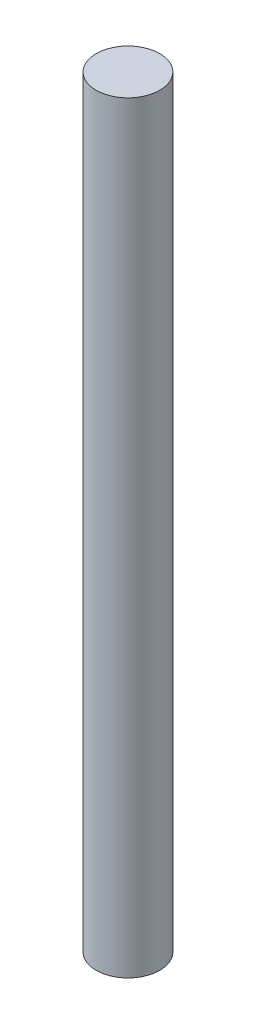
from build123d import *

# Parameters (mm, degrees)
SKETCH1_R           = 30
BOSS_EXTRUDE1_DEPTH = 720


with BuildPart() as part:
    # Sketch1 → Boss-Extrude1 (new body)
    with BuildSketch(Plane(origin=(0, 0, 0), x_dir=(1, 0, 0), z_dir=(0, 1, 0))):
        Circle(SKETCH1_R)
    extrude(amount=BOSS_EXTRUDE1_DEPTH)


solid = part.part
